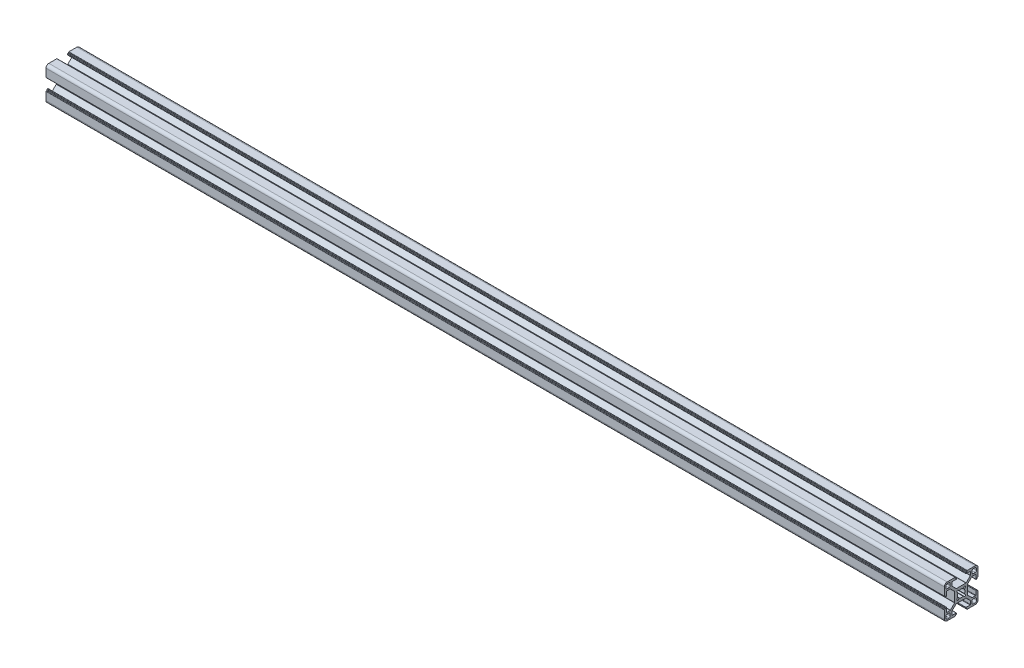
from build123d import *

# Parameters (mm, degrees)
BOSS_EXTRUDE1_DEPTH = 800


with BuildPart() as part:
    # Sketch1 → Boss-Extrude1 (new body)
    with BuildSketch(Plane(origin=(0, 0, 0), x_dir=(0, 0, -1), z_dir=(1, 0, 0))):
        with BuildLine():
            Line((-8.25, 9.788477631), (-8.25, 12.7))
            ThreePointArc((-8.25, 12.7), (-8.162132034, 12.912132034), (-7.95, 13))
            Line((-7.95, 13), (-4.4, 13))
            ThreePointArc((-4.4, 13), (-4.187867966, 13.087867966), (-4.1, 13.3))
            Line((-4.1, 13.3), (-4.1, 13.7))
            ThreePointArc((-4.1, 13.7), (-4.187867966, 13.912132034), (-4.4, 14))
            Line((-4.4, 14), (-4.8, 14))
            ThreePointArc((-4.8, 14), (-5.012132034, 14.087867966), (-5.1, 14.3))
            Line((-5.1, 14.3), (-5.1, 14.7))
            ThreePointArc((-5.1, 14.7), (-5.187867966, 14.912132034), (-5.4, 15))
            Line((-5.4, 15), (-12.5, 15))
            ThreePointArc((-12.5, 15), (-14.267766953, 14.267766953), (-15, 12.5))
            Line((-15, 12.5), (-15, 5.4))
            ThreePointArc((-15, 5.4), (-14.912132034, 5.187867966), (-14.7, 5.1))
            Line((-14.7, 5.1), (-14.3, 5.1))
            ThreePointArc((-14.3, 5.1), (-14.087867966, 5.012132034), (-14, 4.8))
            Line((-14, 4.8), (-14, 4.4))
            ThreePointArc((-14, 4.4), (-13.912132034, 4.187867966), (-13.7, 4.1))
            Line((-13.7, 4.1), (-13.3, 4.1))
            ThreePointArc((-13.3, 4.1), (-13.087867966, 4.187867966), (-13, 4.4))
            Line((-13, 4.4), (-13, 7.95))
            ThreePointArc((-13, 7.95), (-12.912132034, 8.162132034), (-12.7, 8.25))
            Line((-12.7, 8.25), (-9.788477631, 8.25))
            ThreePointArc((-9.788477631, 8.25), (-9.673672601, 8.22716386), (-9.576345597, 8.162132034))
            Line((-9.576345597, 8.162132034), (-5.887867966, 4.473654403))
            ThreePointArc((-5.887867966, 4.473654403), (-5.82283614, 4.376327399), (-5.8, 4.261522369))
            Line((-5.8, 4.261522369), (-5.8, -4.261522369))
            ThreePointArc((-5.8, -4.261522369), (-5.82283614, -4.376327399), (-5.887867966, -4.473654403))
            Line((-5.887867966, -4.473654403), (-9.576345597, -8.162132034))
            ThreePointArc((-9.576345597, -8.162132034), (-9.673672601, -8.22716386), (-9.788477631, -8.25))
            Line((-9.788477631, -8.25), (-12.7, -8.25))
            ThreePointArc((-12.7, -8.25), (-12.912132034, -8.162132034), (-13, -7.95))
            Line((-13, -7.95), (-13, -4.4))
            ThreePointArc((-13, -4.4), (-13.087867966, -4.187867966), (-13.3, -4.1))
            Line((-13.3, -4.1), (-13.7, -4.1))
            ThreePointArc((-13.7, -4.1), (-13.912132034, -4.187867966), (-14, -4.4))
            Line((-14, -4.4), (-14, -4.8))
            ThreePointArc((-14, -4.8), (-14.087867966, -5.012132034), (-14.3, -5.1))
            Line((-14.3, -5.1), (-14.7, -5.1))
            ThreePointArc((-14.7, -5.1), (-14.912132034, -5.187867966), (-15, -5.4))
            Line((-15, -5.4), (-15, -12.5))
            ThreePointArc((-15, -12.5), (-14.267766953, -14.267766953), (-12.5, -15))
            Line((-12.5, -15), (-5.4, -15))
            ThreePointArc((-5.4, -15), (-5.187867966, -14.912132034), (-5.1, -14.7))
            Line((-5.1, -14.7), (-5.1, -14.3))
            ThreePointArc((-5.1, -14.3), (-5.012132034, -14.087867966), (-4.8, -14))
            Line((-4.8, -14), (-4.4, -14))
            ThreePointArc((-4.4, -14), (-4.187867966, -13.912132034), (-4.1, -13.7))
            Line((-4.1, -13.7), (-4.1, -13.3))
            ThreePointArc((-4.1, -13.3), (-4.187867966, -13.087867966), (-4.4, -13))
            Line((-4.4, -13), (-7.95, -13))
            ThreePointArc((-7.95, -13), (-8.162132034, -12.912132034), (-8.25, -12.7))
            Line((-8.25, -12.7), (-8.25, -9.788477631))
            ThreePointArc((-8.25, -9.788477631), (-8.22716386, -9.673672601), (-8.162132034, -9.576345597))
            Line((-8.162132034, -9.576345597), (-4.473654403, -5.887867966))
            ThreePointArc((-4.473654403, -5.887867966), (-4.376327399, -5.82283614), (-4.261522369, -5.8))
            Line((-4.261522369, -5.8), (4.261522369, -5.8))
            ThreePointArc((4.261522369, -5.8), (4.376327399, -5.82283614), (4.473654403, -5.887867966))
            Line((4.473654403, -5.887867966), (8.162132034, -9.576345597))
            ThreePointArc((8.162132034, -9.576345597), (8.22716386, -9.673672601), (8.25, -9.788477631))
            Line((8.25, -9.788477631), (8.25, -12.7))
            ThreePointArc((8.25, -12.7), (8.162132034, -12.912132034), (7.95, -13))
            Line((7.95, -13), (4.4, -13))
            ThreePointArc((4.4, -13), (4.187867966, -13.087867966), (4.1, -13.3))
            Line((4.1, -13.3), (4.1, -13.7))
            ThreePointArc((4.1, -13.7), (4.187867966, -13.912132034), (4.4, -14))
            Line((4.4, -14), (4.8, -14))
            ThreePointArc((4.8, -14), (5.012132034, -14.087867966), (5.1, -14.3))
            Line((5.1, -14.3), (5.1, -14.7))
            ThreePointArc((5.1, -14.7), (5.187867966, -14.912132034), (5.4, -15))
            Line((5.4, -15), (12.5, -15))
            ThreePointArc((12.5, -15), (14.267766953, -14.267766953), (15, -12.5))
            Line((15, -12.5), (15, -5.4))
            ThreePointArc((15, -5.4), (14.912132034, -5.187867966), (14.7, -5.1))
            Line((14.7, -5.1), (14.3, -5.1))
            ThreePointArc((14.3, -5.1), (14.087867966, -5.012132034), (14, -4.8))
            Line((14, -4.8), (14, -4.4))
            ThreePointArc((14, -4.4), (13.912132034, -4.187867966), (13.7, -4.1))
            Line((13.7, -4.1), (13.3, -4.1))
            ThreePointArc((13.3, -4.1), (13.087867966, -4.187867966), (13, -4.4))
            Line((13, -4.4), (13, -7.95))
            ThreePointArc((13, -7.95), (12.912132034, -8.162132034), (12.7, -8.25))
            Line((12.7, -8.25), (9.788477631, -8.25))
            ThreePointArc((9.788477631, -8.25), (9.673672601, -8.22716386), (9.576345597, -8.162132034))
            Line((9.576345597, -8.162132034), (5.887867966, -4.473654403))
            ThreePointArc((5.887867966, -4.473654403), (5.82283614, -4.376327399), (5.8, -4.261522369))
            Line((5.8, -4.261522369), (5.8, 4.261522369))
            ThreePointArc((5.8, 4.261522369), (5.82283614, 4.376327399), (5.887867966, 4.473654403))
            Line((5.887867966, 4.473654403), (9.576345597, 8.162132034))
            ThreePointArc((9.576345597, 8.162132034), (9.673672601, 8.22716386), (9.788477631, 8.25))
            Line((9.788477631, 8.25), (12.7, 8.25))
            ThreePointArc((12.7, 8.25), (12.912132034, 8.162132034), (13, 7.95))
            Line((13, 7.95), (13, 4.4))
            ThreePointArc((13, 4.4), (13.087867966, 4.187867966), (13.3, 4.1))
            Line((13.3, 4.1), (13.7, 4.1))
            ThreePointArc((13.7, 4.1), (13.912132034, 4.187867966), (14, 4.4))
            Line((14, 4.4), (14, 4.8))
            ThreePointArc((14, 4.8), (14.087867966, 5.012132034), (14.3, 5.1))
            Line((14.3, 5.1), (14.7, 5.1))
            ThreePointArc((14.7, 5.1), (14.912132034, 5.187867966), (15, 5.4))
            Line((15, 5.4), (15, 12.5))
            ThreePointArc((15, 12.5), (14.267766953, 14.267766953), (12.5, 15))
            Line((12.5, 15), (5.4, 15))
            ThreePointArc((5.4, 15), (5.187867966, 14.912132034), (5.1, 14.7))
            Line((5.1, 14.7), (5.1, 14.3))
            ThreePointArc((5.1, 14.3), (5.012132034, 14.087867966), (4.8, 14))
            Line((4.8, 14), (4.4, 14))
            ThreePointArc((4.4, 14), (4.187867966, 13.912132034), (4.1, 13.7))
            Line((4.1, 13.7), (4.1, 13.3))
            ThreePointArc((4.1, 13.3), (4.187867966, 13.087867966), (4.4, 13))
            Line((4.4, 13), (7.95, 13))
            ThreePointArc((7.95, 13), (8.162132034, 12.912132034), (8.25, 12.7))
            Line((8.25, 12.7), (8.25, 9.788477631))
            ThreePointArc((8.25, 9.788477631), (8.22716386, 9.673672601), (8.162132034, 9.576345597))
            Line((8.162132034, 9.576345597), (4.473654403, 5.887867966))
            ThreePointArc((4.473654403, 5.887867966), (4.376327399, 5.82283614), (4.261522369, 5.8))
            Line((4.261522369, 5.8), (-4.261522369, 5.8))
            ThreePointArc((-4.261522369, 5.8), (-4.376327399, 5.82283614), (-4.473654403, 5.887867966))
            Line((-4.473654403, 5.887867966), (-8.162132034, 9.576345597))
            ThreePointArc((-8.162132034, 9.576345597), (-8.22716386, 9.673672601), (-8.25, 9.788477631))
        make_face()
        with BuildLine():
            Line((3.05514787, -1.904659815), (3.741964502, -2.698343541))
            ThreePointArc((3.741964502, -2.698343541), (3.70396732, -3.720635173), (2.68151539, -3.75404201))
            Line((2.68151539, -3.75404201), (1.890923385, -3.06366876))
            ThreePointArc((1.890923385, -3.06366876), (1.729867527, -2.991839768), (1.556279141, -3.022911715))
            ThreePointArc((1.556279141, -3.022911715), (0, -3.4), (-1.55627914, -3.022911715))
            ThreePointArc((-1.55627914, -3.022911715), (-1.729867526, -2.991839768), (-1.890923385, -3.06366876))
            Line((-1.890923385, -3.06366876), (-2.68151539, -3.75404201))
            ThreePointArc((-2.68151539, -3.75404201), (-3.70396732, -3.720635173), (-3.741964502, -2.698343541))
            Line((-3.741964502, -2.698343541), (-3.05514787, -1.904659815))
            ThreePointArc((-3.05514787, -1.904659815), (-2.984042722, -1.743283077), (-3.015893746, -1.56983595))
            ThreePointArc((-3.015893746, -1.56983595), (-3.4, 0), (-3.015893746, 1.56983595))
            ThreePointArc((-3.015893746, 1.56983595), (-2.984042722, 1.743283077), (-3.05514787, 1.904659815))
            Line((-3.05514787, 1.904659815), (-3.741964502, 2.698343541))
            ThreePointArc((-3.741964502, 2.698343541), (-3.70396732, 3.720635173), (-2.68151539, 3.75404201))
            Line((-2.68151539, 3.75404201), (-1.890923385, 3.06366876))
            ThreePointArc((-1.890923385, 3.06366876), (-1.729867526, 2.991839768), (-1.55627914, 3.022911715))
            ThreePointArc((-1.55627914, 3.022911715), (0, 3.4), (1.556279141, 3.022911715))
            ThreePointArc((1.556279141, 3.022911715), (1.729867527, 2.991839768), (1.890923385, 3.06366876))
            Line((1.890923385, 3.06366876), (2.68151539, 3.75404201))
            ThreePointArc((2.68151539, 3.75404201), (3.70396732, 3.720635173), (3.741964502, 2.698343541))
            Line((3.741964502, 2.698343541), (3.05514787, 1.904659815))
            ThreePointArc((3.05514787, 1.904659815), (2.984042722, 1.743283077), (3.015893747, 1.56983595))
            ThreePointArc((3.015893747, 1.56983595), (3.4, 0), (3.015893747, -1.56983595))
            ThreePointArc((3.015893747, -1.56983595), (2.984042722, -1.743283077), (3.05514787, -1.904659815))
        make_face(mode=Mode.SUBTRACT)
        with BuildLine():
            Line((10.75, -9.75), (12.65, -9.75))
            ThreePointArc((12.65, -9.75), (13.357106781, -10.042893219), (13.65, -10.75))
            Line((13.65, -10.75), (13.65, -12.15))
            ThreePointArc((13.65, -12.15), (13.210660172, -13.210660172), (12.15, -13.65))
            Line((12.15, -13.65), (10.75, -13.65))
            ThreePointArc((10.75, -13.65), (10.042893219, -13.357106781), (9.75, -12.65))
            Line((9.75, -12.65), (9.75, -10.75))
            ThreePointArc((9.75, -10.75), (10.042893219, -10.042893219), (10.75, -9.75))
        make_face(mode=Mode.SUBTRACT)
        with BuildLine():
            Line((-10.75, 9.75), (-12.65, 9.75))
            ThreePointArc((-12.65, 9.75), (-13.357106781, 10.042893219), (-13.65, 10.75))
            Line((-13.65, 10.75), (-13.65, 12.15))
            ThreePointArc((-13.65, 12.15), (-13.210660172, 13.210660172), (-12.15, 13.65))
            Line((-12.15, 13.65), (-10.75, 13.65))
            ThreePointArc((-10.75, 13.65), (-10.042893219, 13.357106781), (-9.75, 12.65))
            Line((-9.75, 12.65), (-9.75, 10.75))
            ThreePointArc((-9.75, 10.75), (-10.042893219, 10.042893219), (-10.75, 9.75))
        make_face(mode=Mode.SUBTRACT)
        with BuildLine():
            Line((9.75, 10.75), (9.75, 12.65))
            ThreePointArc((9.75, 12.65), (10.042893219, 13.357106781), (10.75, 13.65))
            Line((10.75, 13.65), (12.15, 13.65))
            ThreePointArc((12.15, 13.65), (13.210660172, 13.210660172), (13.65, 12.15))
            Line((13.65, 12.15), (13.65, 10.75))
            ThreePointArc((13.65, 10.75), (13.357106781, 10.042893219), (12.65, 9.75))
            Line((12.65, 9.75), (10.75, 9.75))
            ThreePointArc((10.75, 9.75), (10.042893219, 10.042893219), (9.75, 10.75))
        make_face(mode=Mode.SUBTRACT)
        with BuildLine():
            Line((-9.75, -10.75), (-9.75, -12.65))
            ThreePointArc((-9.75, -12.65), (-10.042893219, -13.357106781), (-10.75, -13.65))
            Line((-10.75, -13.65), (-12.15, -13.65))
            ThreePointArc((-12.15, -13.65), (-13.210660172, -13.210660172), (-13.65, -12.15))
            Line((-13.65, -12.15), (-13.65, -10.75))
            ThreePointArc((-13.65, -10.75), (-13.357106781, -10.042893219), (-12.65, -9.75))
            Line((-12.65, -9.75), (-10.75, -9.75))
            ThreePointArc((-10.75, -9.75), (-10.042893219, -10.042893219), (-9.75, -10.75))
        make_face(mode=Mode.SUBTRACT)
    extrude(amount=BOSS_EXTRUDE1_DEPTH)


solid = part.part
